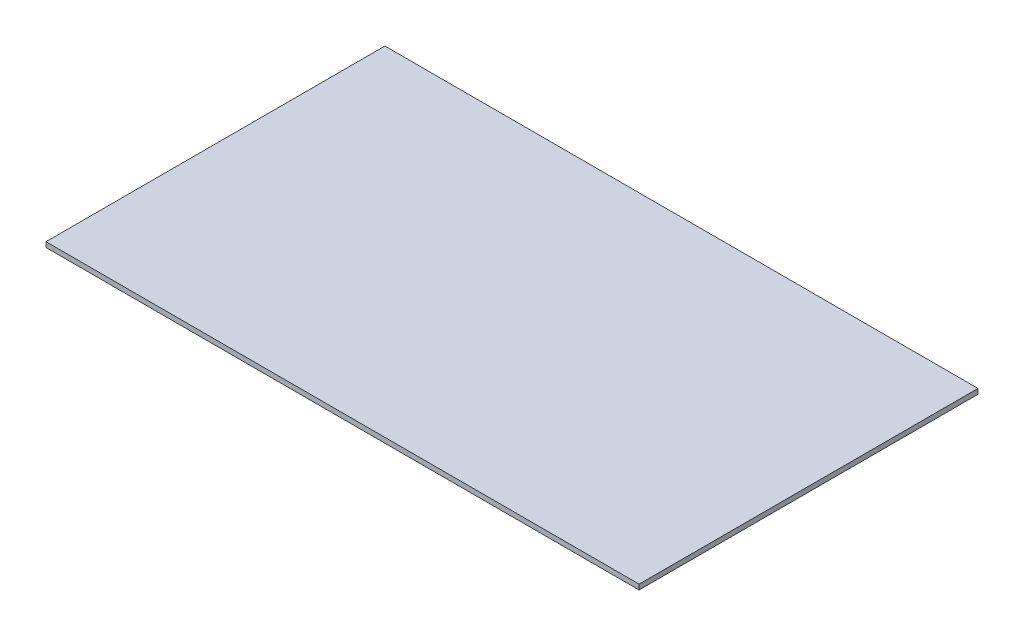
from build123d import *

# Parameters (mm, degrees)
SKETCH1_W           = 350
SKETCH1_H           = 200
BOSS_EXTRUDE1_DEPTH = 3


with BuildPart() as part:
    # Sketch1 → Boss-Extrude1 (new body)
    with BuildSketch(Plane(origin=(0, 0, 0), x_dir=(1, 0, 0), z_dir=(0, 1, 0))):
        with Locations((175, 100)):
            Rectangle(SKETCH1_W, SKETCH1_H)
    extrude(amount=BOSS_EXTRUDE1_DEPTH)


solid = part.part
